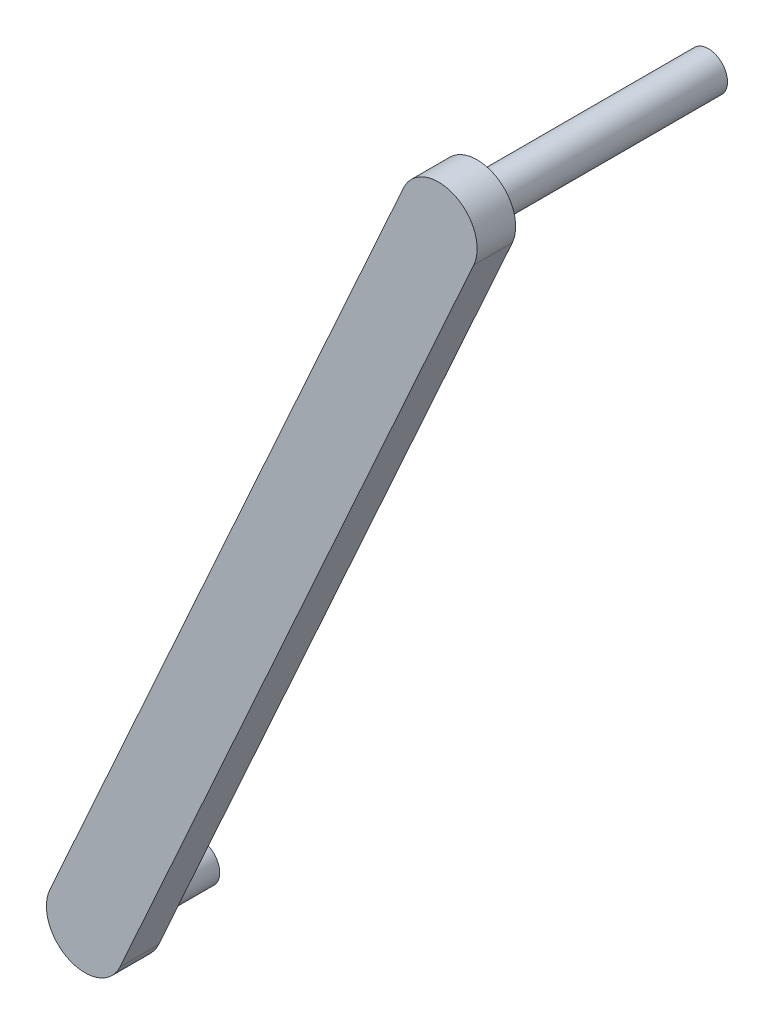
from build123d import *

# Parameters (mm, degrees)
BOSS_EXTRUDE1_DEPTH = 2
SKETCH1_3_R         = 1
BOSS_EXTRUDE2_DEPTH = 4
SKETCH1_4_R         = 1
BOSS_EXTRUDE3_DEPTH = 12


with BuildPart() as part:
    # Sketch1 → Boss-Extrude1 (new body)
    with BuildSketch(Plane.XY.offset(14.87534902)):
        with BuildLine():
            Line((2.748026099, -19.086356488), (-15.614663255, -59.821649221))
            ThreePointArc((-15.614663255, -59.821649221), (-18.259886239, -60.823045928), (-19.261282946, -58.177822944))
            Line((-19.261282946, -58.177822944), (-0.898593592, -17.442530211))
            ThreePointArc((-0.898593592, -17.442530211), (1.746629392, -16.441133504), (2.748026099, -19.086356488))
        make_face()
    extrude(amount=BOSS_EXTRUDE1_DEPTH)

    # Sketch1_3 → Boss-Extrude2 (add)
    with BuildSketch(Plane.XY.offset(14.87534902)):
        with Locations((-17.4379731, -58.999736083)):
            Circle(SKETCH1_3_R)
    extrude(amount=-BOSS_EXTRUDE2_DEPTH)

    # Sketch1_4 → Boss-Extrude3 (add)
    with BuildSketch(Plane.XY.offset(14.87534902)):
        with Locations((0.924716254, -18.26444335)):
            Circle(SKETCH1_4_R)
    extrude(amount=-BOSS_EXTRUDE3_DEPTH)


solid = part.part
